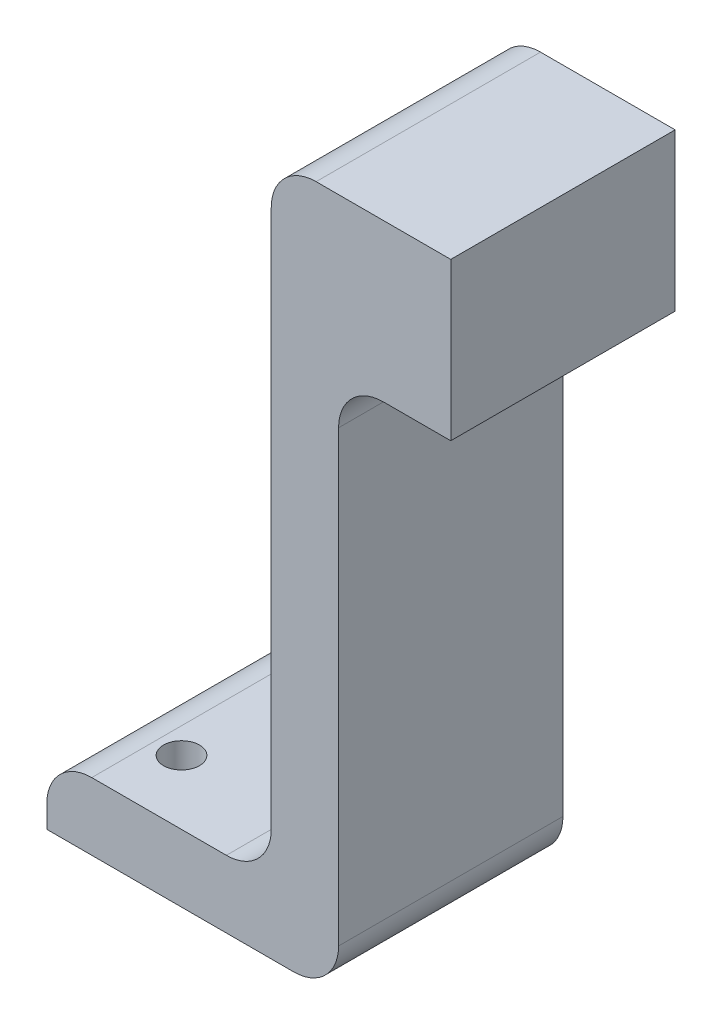
from build123d import *

# Parameters (mm, degrees)
SKETCH1_W                  = 2.5
SKETCH1_H                  = 0.75
BOSS_EXTRUDE1_DEPTH        = 1.875
BOSS_EXTRUDE1_DEPTH_BACK   = 0.625
FILLET1_R                  = 0.5
F_0_4_0_4_DIAMETER_HOLE1_D = 0.4


with BuildPart() as part:
    # Sketch1 → Boss-Extrude1 (new body, two sides)
    with BuildSketch(Plane.XY) as boss_extrude1_sk:
        Polygon((0.285769435, 0.25), (-0.464230565, 0.25), (-0.464230565, -5), (-0.464230565, -5.75), (0.285769435, -5.75), align=None)
        Polygon((-0.464230565, 2), (-0.464230565, 0.25), (0.285769435, 0.25), (1.535769435, 0.25), (1.535769435, 2), align=None)
        with Locations((-1.714230565, -5.375)):
            Rectangle(SKETCH1_W, SKETCH1_H)
    extrude(amount=BOSS_EXTRUDE1_DEPTH)
    extrude(boss_extrude1_sk.sketch, amount=-BOSS_EXTRUDE1_DEPTH_BACK)

    # Fillet1
    fillet1_edges = [part.edges().sort_by_distance(p)[0] for p in [
        (0.285769435, 0.25, 0.625),
        (-2.964230565, -5, 0.625),
        (-0.464230565, -5, 0.625),
        (0.285769435, -5.75, 0.625),
        (-0.464230565, 2, 0.625),
    ]]
    fillet(fillet1_edges, radius=FILLET1_R)

    # Ø0.4 (0.4) Diameter Hole1 (through all)
    with Locations(Plane(origin=(0, -5, 0), x_dir=(1, 0, 0), z_dir=(0, 1, 0))):
        with Locations((-1.714230565, 0), (-2.17846891, -1.160595864)):
            Hole(F_0_4_0_4_DIAMETER_HOLE1_D / 2)


solid = part.part
